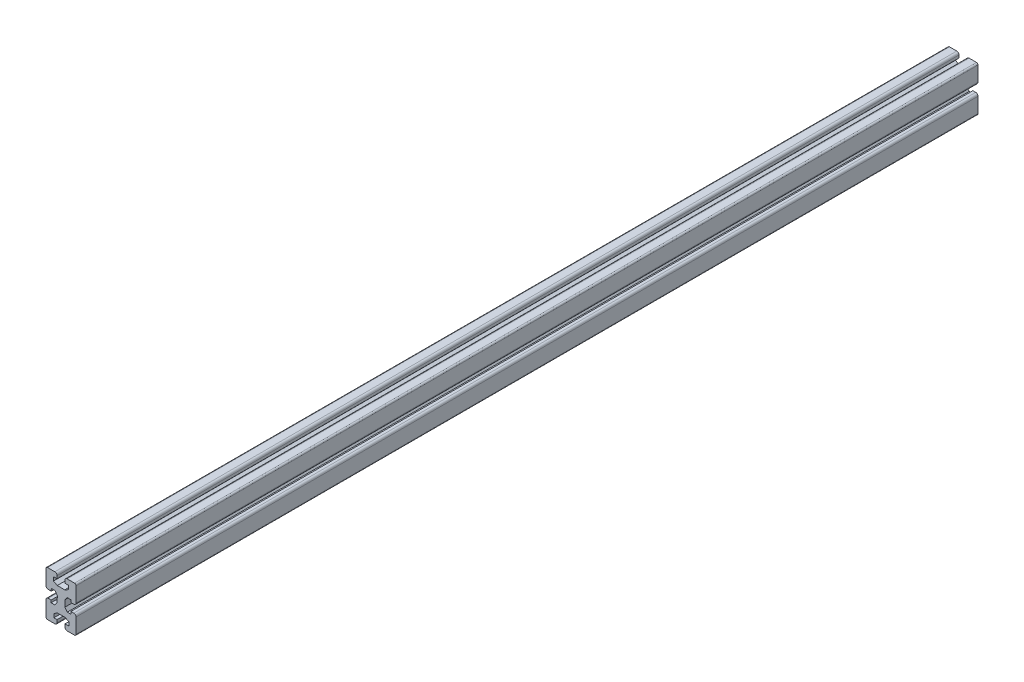
from build123d import *

# Parameters (mm, degrees)
SALIENTE_EXTRUIR1_DEPTH    = 1200
REDONDEO3_R                = 2
REDONDEO4_R                = 3
CORTAR_EXTRUIR1_DEPTH      = 1200
CROQUIS3_R                 = 3
CORTAR_EXTRUIR2_DEPTH      = 56
CORTAR_EXTRUIR2_DEPTH_BACK = 96


with BuildPart() as part:
    # Croquis1 → Saliente-Extruir1 (new body)
    with BuildSketch(Plane.XY):
        Polygon((20, -30), (5.2, -30), (5.2, -20), (-5.2, -20), (-5.2, -30), (-20, -30), (-20, -5), (-10, -5), (-10, 5.215), (-20, 5.215), (-20, 30), (-5.2, 30), (-5.2, 20), (5.2, 20), (5.2, 30), (20, 30), (20, 5.215), (10, 5.215), (10, -5), (20, -5), align=None)
    extrude(amount=SALIENTE_EXTRUIR1_DEPTH)

    # Redondeo3
    redondeo3_edges = [part.edges().sort_by_distance(p)[0] for p in [
        (-20, -30, 600),
        (-20, 30, 600),
        (20, 30, 600),
        (20, -30, 600),
    ]]
    fillet(redondeo3_edges, radius=REDONDEO3_R)

    # Redondeo4
    redondeo4_edges = [part.edges().sort_by_distance(p)[0] for p in [
        (-5.2, -30, 600),
        (-20, -5, 600),
        (-20, 5.215, 600),
        (-5.2, 30, 600),
        (5.2, 30, 600),
        (20, 5.215, 600),
        (20, -5, 600),
        (5.2, -30, 600),
    ]]
    fillet(redondeo4_edges, radius=REDONDEO4_R)

    # Croquis2 → Cortar-Extruir1 (cut)
    with BuildSketch(Plane.XY.offset(1200)):
        Polygon((-10, 23.452026666), (10, 23.452026666), (10, 18.452026666), (5, 15.75606021), (-5, 15.75606021), (-10, 18.452026666), align=None)
        Polygon((-9.601016284, -18.662737591), (-4.660128357, -15.859906589), (5.33756066, -15.644931432), (10.39436175, -18.232787277), (10.501849328, -23.231631786), (-9.493528706, -23.6615821), align=None)
        Polygon((13, 8.477670191), (8.105479793, 8.477670191), (5, 4.292585096), (5.091124424, -4.184105508), (8.285855478, -8.301463337), (13.17924457, -8.196243312), align=None)
        Polygon((-13, 8.477670191), (-8.105479793, 8.477670191), (-5, 4.292585096), (-5.091124424, -4.184105508), (-8.285855478, -8.301463337), (-13.17924457, -8.196243312), align=None)
    extrude(amount=-CORTAR_EXTRUIR1_DEPTH, mode=Mode.SUBTRACT)

    # Croquis3 → Cortar-Extruir2 (cut, two sides)
    with BuildSketch(Plane(origin=(5.045562212, 0.054239794, 0), x_dir=(0, 0, -1), z_dir=(0.999942224, 0.010749379, 0))) as cortar_extruir2_sk:
        with Locations((-1182, 0)):
            Circle(CROQUIS3_R)
        with Locations((-18, 0)):
            Circle(CROQUIS3_R)
    extrude(amount=CORTAR_EXTRUIR2_DEPTH, mode=Mode.SUBTRACT)
    extrude(cortar_extruir2_sk.sketch, amount=-CORTAR_EXTRUIR2_DEPTH_BACK, mode=Mode.SUBTRACT)


solid = part.part
